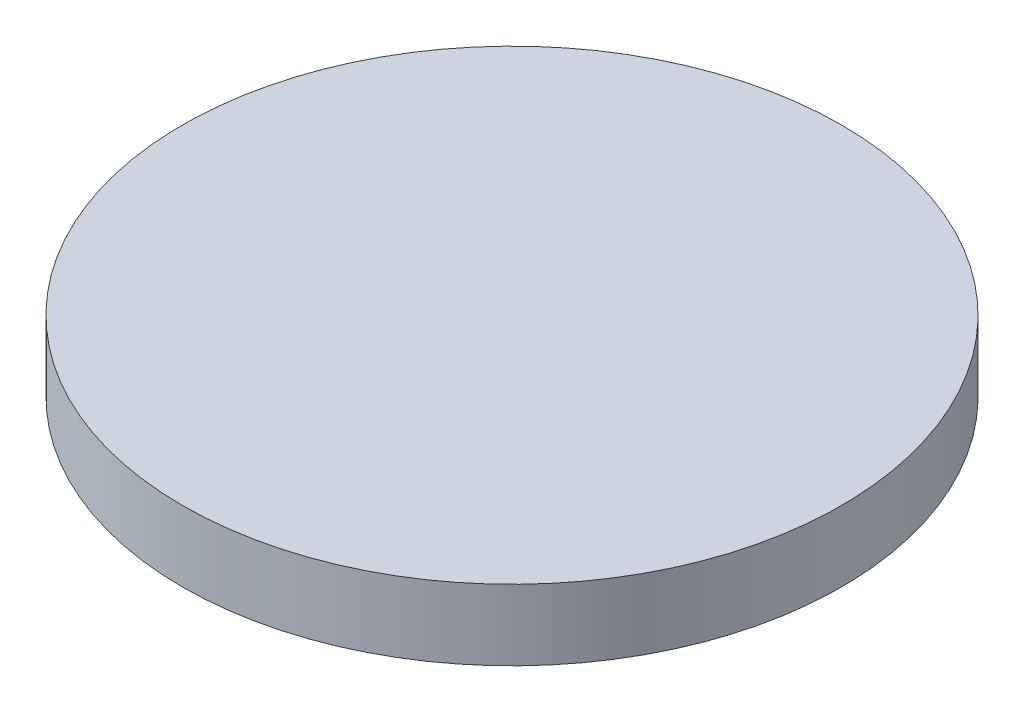
from build123d import *

# Parameters (mm, degrees)
SKETCH1_R           = 44.45
BOSS_EXTRUDE1_DEPTH = 4.7625


with BuildPart() as part:
    # Sketch1 → Boss-Extrude1 (new body, symmetric)
    with BuildSketch(Plane(origin=(0, 0, 0), x_dir=(1, 0, 0), z_dir=(0, 1, 0))):
        Circle(SKETCH1_R)
    extrude(amount=BOSS_EXTRUDE1_DEPTH, both=True)


solid = part.part
